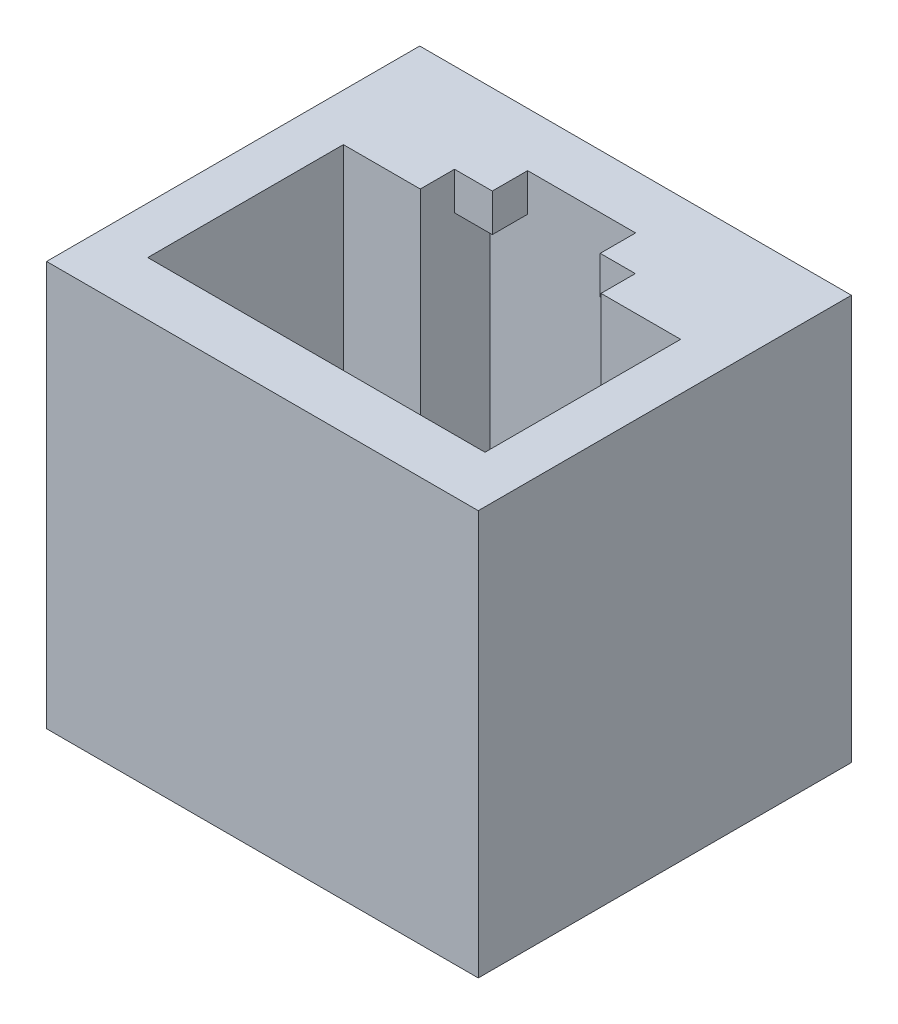
from build123d import *

# Parameters (mm, degrees)
SKETCH1_W           = 16
SKETCH1_H           = 13.83
BOSS_EXTRUDE1_DEPTH = 25
SKETCH2_W           = 1
SKETCH2_H           = 1.15
BOSS_EXTRUDE3_DEPTH = 16.73
SKETCH3_W           = 1.4
SKETCH3_H           = 1.31
SKETCH3_W_2         = 1.3
CUT_EXTRUDE1_DEPTH  = 23.6
SKETCH5_W           = 16
SKETCH5_H           = 13.83
CUT_EXTRUDE2_DEPTH  = 10


with BuildPart() as part:
    # Sketch1 → Boss-Extrude1 (new body)
    with BuildSketch(Plane(origin=(0, 0, 0), x_dir=(1, 0, 0), z_dir=(0, 1, 0))):
        with Locations((6.25, 4.915)):
            Rectangle(SKETCH1_W, SKETCH1_H)
        Polygon((0, 0), (0, 7.25), (2.85, 7.25), (2.85, 8.52), (4.25, 8.52), (4.25, 9.83), (8.25, 9.83), (8.25, 8.52), (9.55, 8.52), (9.55, 7.25), (12.5, 7.25), (12.5, 0), align=None, mode=Mode.SUBTRACT)
    extrude(amount=BOSS_EXTRUDE1_DEPTH)

    # Sketch2 → Boss-Extrude3 (add)
    with BuildSketch(Plane.XZ):
        with Locations((12, -6.675)):
            Rectangle(SKETCH2_W, SKETCH2_H)
        with Locations((0.5, -6.675)):
            Rectangle(SKETCH2_W, SKETCH2_H)
    extrude(amount=-BOSS_EXTRUDE3_DEPTH)

    # Sketch3 → Cut-Extrude1 (cut)
    with BuildSketch(Plane.XZ):
        with Locations((3.55, -9.175)):
            Rectangle(SKETCH3_W, SKETCH3_H)
        with Locations((8.9, -9.175)):
            Rectangle(SKETCH3_W_2, SKETCH3_H)
    extrude(amount=-CUT_EXTRUDE1_DEPTH, mode=Mode.SUBTRACT)

    # Sketch5 → Cut-Extrude2 (cut)
    with BuildSketch(Plane.XZ):
        with Locations((6.25, -4.915)):
            Rectangle(SKETCH5_W, SKETCH5_H)
    extrude(amount=-CUT_EXTRUDE2_DEPTH, mode=Mode.SUBTRACT)


solid = part.part
